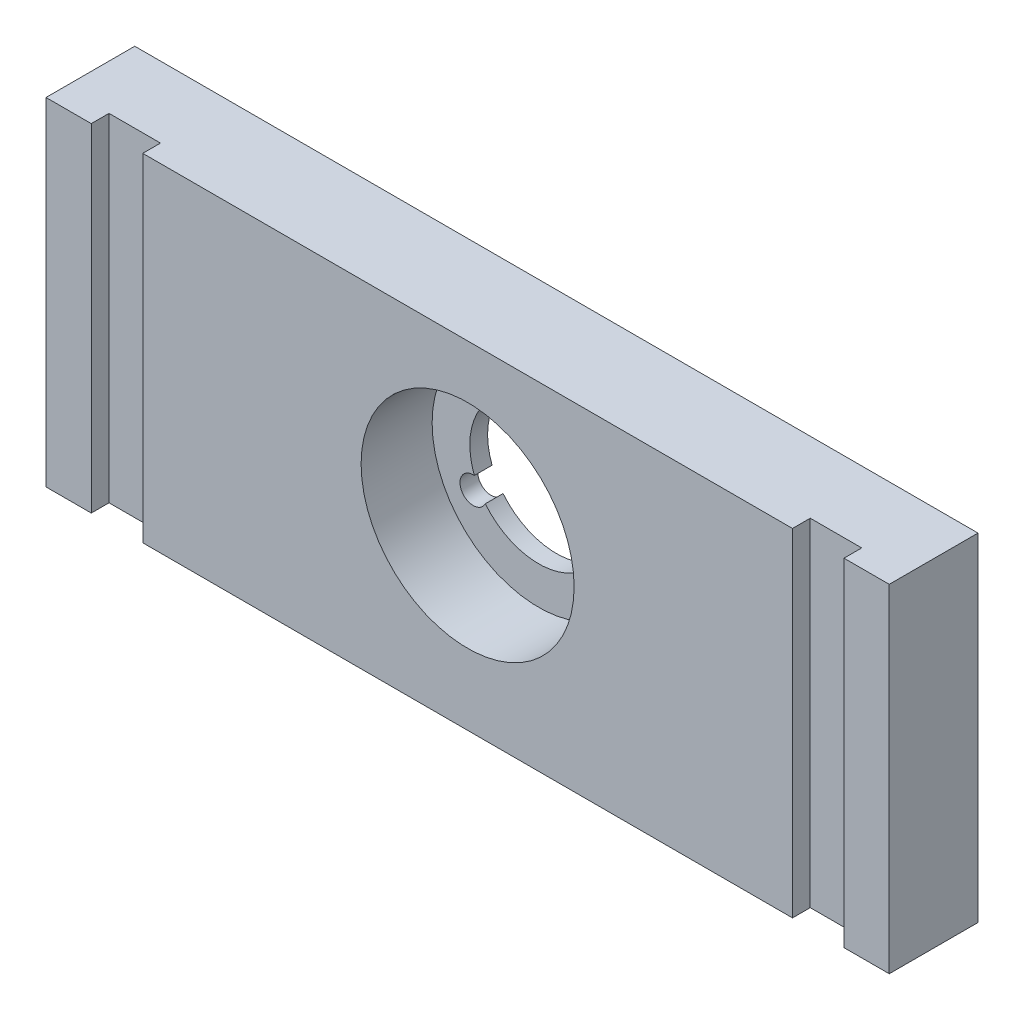
from build123d import *

# Parameters (mm, degrees)
ESQUISSE1_W      = 95
ESQUISSE1_H      = 38
EXTRUSION1_DEPTH = 10
ESQUISSE3_R      = 12
EXTRUSION3_DEPTH = 8
ESQUISSE4_W      = 5.8
ESQUISSE4_H      = 38
EXTRUSION4_DEPTH = 2


with BuildPart() as part:
    # Esquisse1 → Extrusion1 (new body)
    with BuildSketch(Plane.XY):
        with Locations((47.5, -19)):
            Rectangle(ESQUISSE1_W, ESQUISSE1_H)
        with BuildLine():
            ThreePointArc((46.263573917, -10.349264706), (40.788303121, -14.125), (40.256055836, -20.754591249))
            ThreePointArc((40.256055836, -20.754591249), (38.839745962, -23), (41.492481919, -22.896144045))
            ThreePointArc((41.492481919, -22.896144045), (47.5, -25.75), (53.507518081, -22.896144045))
            ThreePointArc((53.507518081, -22.896144045), (56.160254038, -23), (54.743944164, -20.754591249))
            ThreePointArc((54.743944164, -20.754591249), (54.211696879, -14.125), (48.736426083, -10.349264706))
            ThreePointArc((48.736426083, -10.349264706), (47.5, -8), (46.263573917, -10.349264706))
        make_face(mode=Mode.SUBTRACT)
    extrude(amount=EXTRUSION1_DEPTH)

    # Esquisse3 → Extrusion3 (cut)
    with BuildSketch(Plane.XY.offset(10)):
        with Locations((47.5, -18)):
            Circle(ESQUISSE3_R)
    extrude(amount=-EXTRUSION3_DEPTH, mode=Mode.SUBTRACT)

    # Esquisse4 → Extrusion4 (cut)
    with BuildSketch(Plane.XY.offset(10)):
        with Locations((8, -19)):
            Rectangle(ESQUISSE4_W, ESQUISSE4_H)
        with Locations((87, -19)):
            Rectangle(ESQUISSE4_W, ESQUISSE4_H)
    extrude(amount=-EXTRUSION4_DEPTH, mode=Mode.SUBTRACT)


solid = part.part
